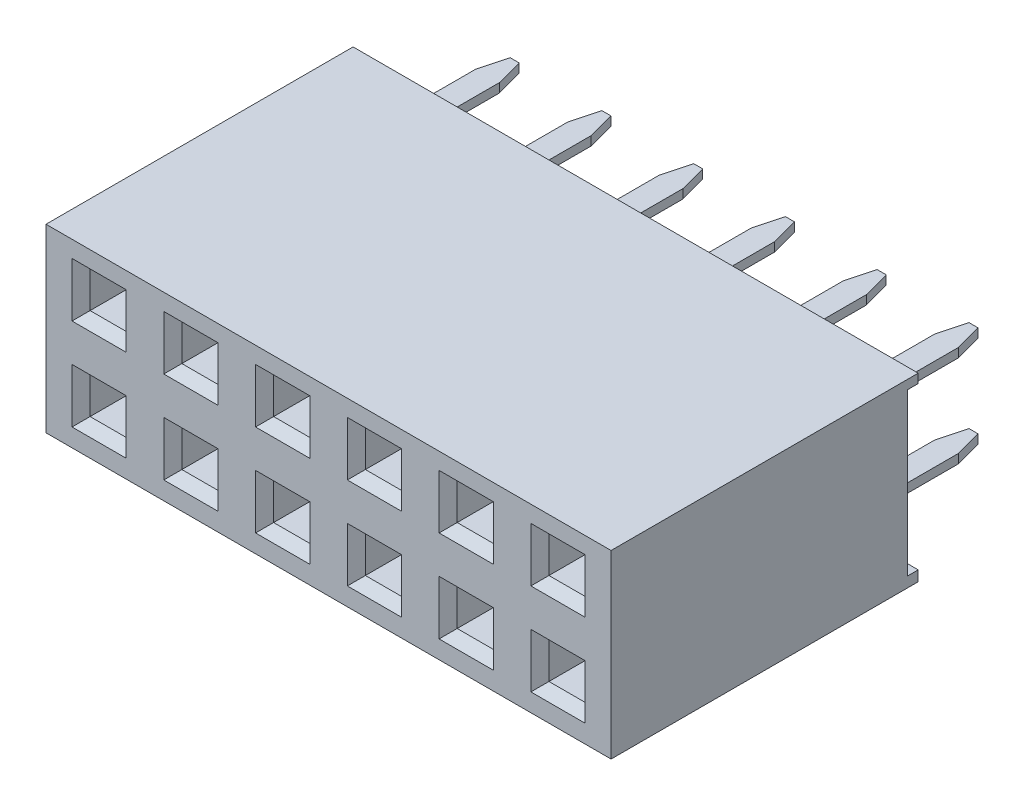
from build123d import *

# Parameters (mm, degrees)
SKETCH1_W                  = 15.64
SKETCH1_H                  = 5
BOSS_EXTRUDE1_DEPTH        = 8.5
SKETCH2_W                  = 1
SKETCH2_H                  = 1
CUT_EXTRUDE1_DEPTH         = 2.25
CHAMFER1_SIZE              = 0.25
SKETCH3_W                  = 0.3
SKETCH3_H                  = 4.463850618
CUT_EXTRUDE2_DEPTH         = 16.64
SKETCH4_W                  = 0.65
SKETCH4_H                  = 3.3
BOSS_EXTRUDE2_DEPTH        = 0.125
CHAMFER2_SIZE              = 0.2
CHAMFER2_SIZE2             = 0.746410162
LPATTERN4_COUNT            = 6
LPATTERN4_PITCH            = 2.54
LPATTERN4_2_COUNT          = 2
LPATTERN4_2_PITCH          = 2.54
LPATTERN5_COUNT            = 6
LPATTERN5_PITCH            = 2.54
LPATTERN5_COUNT_DIR2       = 2
LPATTERN5_PITCH_DIR2       = 2.54
CHAMFER1_OF_LPATTERN5_SIZE = 0.25


with BuildPart() as part:
    # Sketch1 → Boss-Extrude1 (new body)
    with BuildSketch(Plane.XY):
        with Locations((7.82, 2.5)):
            Rectangle(SKETCH1_W, SKETCH1_H)
    extrude(amount=BOSS_EXTRUDE1_DEPTH)

    # Sketch2 → Cut-Extrude1 (cut)
    with BuildSketch(Plane.XY.offset(8.5)):
        with Locations((1.47, 1.25)):
            Rectangle(SKETCH2_W, SKETCH2_H)
    cut_extrude1 = extrude(amount=-CUT_EXTRUDE1_DEPTH, mode=Mode.SUBTRACT)

    # Chamfer1
    chamfer1_edges = [part.edges().sort_by_distance(p)[0] for p in [
        (0.97, 1.25, 8.5),
        (1.47, 0.75, 8.5),
        (1.97, 1.25, 8.5),
        (1.47, 1.75, 8.5),
    ]]
    chamfer(chamfer1_edges, length=CHAMFER1_SIZE)

    # Sketch3 → Cut-Extrude2 (cut, through all)
    with BuildSketch(Plane.ZY):
        with Locations((0.15, 2.518074691)):
            Rectangle(SKETCH3_W, SKETCH3_H)
    extrude(amount=-CUT_EXTRUDE2_DEPTH, mode=Mode.SUBTRACT)

    # LPattern5: Cut-Extrude1 6 × 2
    with Locations(*[(i * LPATTERN5_PITCH, j * LPATTERN5_PITCH_DIR2, 0) for i in range(LPATTERN5_COUNT) for j in range(LPATTERN5_COUNT_DIR2) if (i, j) != (0, 0)]):
        add(cut_extrude1, mode=Mode.SUBTRACT)

    # Chamfer1 of LPattern5
    chamfer1_of_lpattern5_edges = [part.edges().sort_by_distance(p)[0] for p in [
        (0.97, 3.79, 8.5),
        (1.47, 3.29, 8.5),
        (1.97, 3.79, 8.5),
        (1.47, 4.29, 8.5),
        (3.51, 1.25, 8.5),
        (4.01, 0.75, 8.5),
        (4.51, 1.25, 8.5),
        (4.01, 1.75, 8.5),
        (3.51, 3.79, 8.5),
        (4.01, 3.29, 8.5),
        (4.51, 3.79, 8.5),
        (4.01, 4.29, 8.5),
        (6.05, 1.25, 8.5),
        (6.55, 0.75, 8.5),
        (7.05, 1.25, 8.5),
        (6.55, 1.75, 8.5),
        (6.05, 3.79, 8.5),
        (6.55, 3.29, 8.5),
        (7.05, 3.79, 8.5),
        (6.55, 4.29, 8.5),
        (8.59, 1.25, 8.5),
        (9.09, 0.75, 8.5),
        (9.59, 1.25, 8.5),
        (9.09, 1.75, 8.5),
        (8.59, 3.79, 8.5),
        (9.09, 3.29, 8.5),
        (9.59, 3.79, 8.5),
        (9.09, 4.29, 8.5),
        (11.13, 1.25, 8.5),
        (11.63, 0.75, 8.5),
        (12.13, 1.25, 8.5),
        (11.63, 1.75, 8.5),
        (11.13, 3.79, 8.5),
        (11.63, 3.29, 8.5),
        (12.13, 3.79, 8.5),
        (11.63, 4.29, 8.5),
        (13.67, 1.25, 8.5),
        (14.17, 0.75, 8.5),
        (14.67, 1.25, 8.5),
        (14.17, 1.75, 8.5),
        (13.67, 3.79, 8.5),
        (14.17, 3.29, 8.5),
        (14.67, 3.79, 8.5),
        (14.17, 4.29, 8.5),
    ]]
    chamfer(chamfer1_of_lpattern5_edges, length=CHAMFER1_OF_LPATTERN5_SIZE)


with BuildPart() as body_2:
    # Sketch4 → Boss-Extrude2 (new body, symmetric)
    with BuildSketch(Plane(origin=(0, 1.25, 0), x_dir=(-1, 0, 0), z_dir=(0, -1, 0))):
        with Locations((-1.47, 1.35)):
            Rectangle(SKETCH4_W, SKETCH4_H)
    extrude(amount=BOSS_EXTRUDE2_DEPTH, both=True)

    # Chamfer2
    chamfer2_edges = [body_2.edges().sort_by_distance(p)[0] for p in [
        (1.795, 1.25, -3),
        (1.145, 1.25, -3),
    ]]
    chamfer2_side = [body_2.faces().sort_by_distance(p)[0] for p in [
        (1.47, 1.25, -3),
    ]]
    chamfer(chamfer2_edges, length=CHAMFER2_SIZE, length2=CHAMFER2_SIZE2, reference=chamfer2_side[0])


with BuildPart() as lpattern4_1:
    # LPattern4: pattern copy
    add(body_2.part.moved(Location(Vector(1, 0, 0) * (1 * LPATTERN4_PITCH))))


with BuildPart() as lpattern4_2:
    # LPattern4: pattern copy
    add(body_2.part.moved(Location(Vector(1, 0, 0) * (2 * LPATTERN4_PITCH))))


with BuildPart() as lpattern4_3:
    # LPattern4: pattern copy
    add(body_2.part.moved(Location(Vector(1, 0, 0) * (3 * LPATTERN4_PITCH))))


with BuildPart() as lpattern4_4:
    # LPattern4: pattern copy
    add(body_2.part.moved(Location(Vector(1, 0, 0) * (4 * LPATTERN4_PITCH))))


with BuildPart() as lpattern4_5:
    # LPattern4: pattern copy
    add(body_2.part.moved(Location(Vector(1, 0, 0) * (5 * LPATTERN4_PITCH))))


with BuildPart() as lpattern4_2_1:
    # LPattern4 2: pattern copy
    add(body_2.part.moved(Location(Vector(0, 1, 0) * (1 * LPATTERN4_2_PITCH))))


with BuildPart() as lpattern4_2_2:
    # LPattern4 2: pattern copy
    add(lpattern4_1.part.moved(Location(Vector(0, 1, 0) * (1 * LPATTERN4_2_PITCH))))


with BuildPart() as lpattern4_2_3:
    # LPattern4 2: pattern copy
    add(lpattern4_2.part.moved(Location(Vector(0, 1, 0) * (1 * LPATTERN4_2_PITCH))))


with BuildPart() as lpattern4_2_4:
    # LPattern4 2: pattern copy
    add(lpattern4_3.part.moved(Location(Vector(0, 1, 0) * (1 * LPATTERN4_2_PITCH))))


with BuildPart() as lpattern4_2_5:
    # LPattern4 2: pattern copy
    add(lpattern4_4.part.moved(Location(Vector(0, 1, 0) * (1 * LPATTERN4_2_PITCH))))


with BuildPart() as lpattern4_2_6:
    # LPattern4 2: pattern copy
    add(lpattern4_5.part.moved(Location(Vector(0, 1, 0) * (1 * LPATTERN4_2_PITCH))))


solid = Compound([part.part, body_2.part, lpattern4_1.part, lpattern4_2.part, lpattern4_3.part, lpattern4_4.part, lpattern4_5.part, lpattern4_2_1.part, lpattern4_2_2.part, lpattern4_2_3.part, lpattern4_2_4.part, lpattern4_2_5.part, lpattern4_2_6.part])
